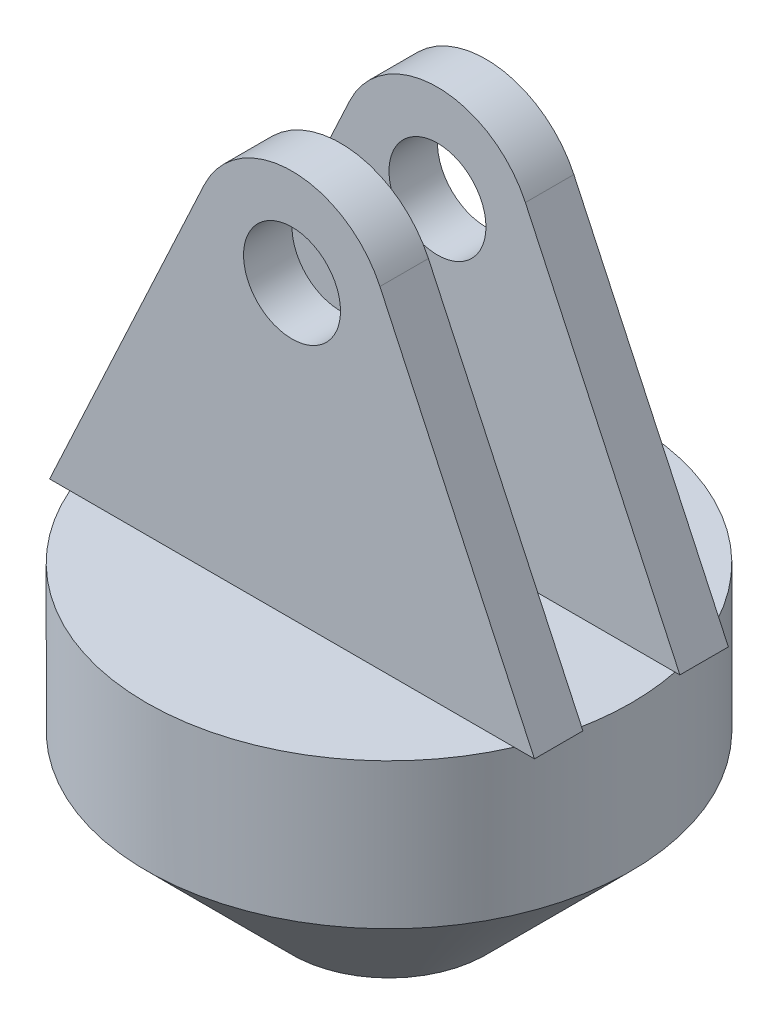
from build123d import *

# Parameters (mm, degrees)
RESSALTO_EXTRUS_O1_START = 10
ESBO_O2_R                = 10
RESSALTO_EXTRUS_O1_DEPTH = 10


with BuildPart() as part:
    # Esboço1 → Revolução1 (revolve)
    with BuildSketch(Plane.XY):
        Polygon((0, 0), (0, 60), (50, 60), (50, 30), (20, 0), align=None)
    revolve(axis=Axis((0, 0, 0), (0, 1, 0)))

    # Esboço2 → Ressalto-extrusão1 (add)
    with BuildSketch(Plane.XY.offset(RESSALTO_EXTRUS_O1_START)):
        with BuildLine():
            Line((50, 60), (18.13082184, 128.442351533))
            ThreePointArc((18.13082184, 128.442351533), (0, 140), (-18.13082184, 128.442351533))
            Line((-18.13082184, 128.442351533), (-50, 60))
            Line((-50, 60), (50, 60))
        make_face()
        with Locations((0, 120)):
            Circle(ESBO_O2_R, mode=Mode.SUBTRACT)
    ressalto_extrus_o1 = extrude(amount=RESSALTO_EXTRUS_O1_DEPTH)

    # Espelhar1: Ressalto-extrusão1 across plane
    add(ressalto_extrus_o1.mirror(Plane.XY))


solid = part.part
